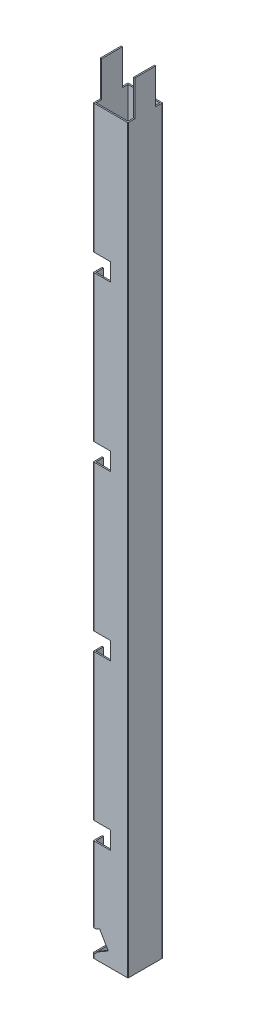
from build123d import *

# Parameters (mm, degrees)
SKETCH1_W           = 37
SKETCH1_H           = 37
BOSS_EXTRUDE1_DEPTH = 899
CUT_EXTRUDE2_DEPTH  = 20
SKETCH4_W           = 8
SKETCH4_H           = 41
CUT_EXTRUDE3_DEPTH  = 901.777997067
SKETCH5_R           = 3.5
CUT_EXTRUDE4_DEPTH  = 10
CUT_EXTRUDE5_DEPTH  = 20


with BuildPart() as part:
    # Sketch1 → Boss-Extrude1 (new body)
    with BuildSketch(Plane(origin=(0, 0, 0), x_dir=(1, 0, 0), z_dir=(0, 1, 0))):
        with BuildLine():
            Line((0.5, 0), (39.5, 0))
            ThreePointArc((39.5, 0), (39.853553391, 0.146446609), (40, 0.5))
            Line((40, 0.5), (40, 39.5))
            ThreePointArc((40, 39.5), (39.853553391, 39.853553391), (39.5, 40))
            Line((39.5, 40), (0.5, 40))
            ThreePointArc((0.5, 40), (0.146446609, 39.853553391), (0, 39.5))
            Line((0, 39.5), (0, 0.5))
            ThreePointArc((0, 0.5), (0.146446609, 0.146446609), (0.5, 0))
        make_face()
        with Locations((20, 20)):
            Rectangle(SKETCH1_W, SKETCH1_H, mode=Mode.SUBTRACT)
    extrude(amount=BOSS_EXTRUDE1_DEPTH)

    # Sketch3 → Cut-Extrude2 (cut)
    with BuildSketch(Plane.XY):
        Polygon((0, 29.014346333), (0, 5.907288086), (3, 5.907288086), (3, 7.639845548), (17.125490967, 15.797587142), (7.072929751, 33.098592085), (3, 30.74639714), (0, 30.74639714), align=None)
    extrude(amount=-CUT_EXTRUDE2_DEPTH, mode=Mode.SUBTRACT)

    # Sketch4 → Cut-Extrude3 (cut, through all)
    with BuildSketch(Plane.ZY):
        with Locations((-4, 878.5)):
            Rectangle(SKETCH4_W, SKETCH4_H)
        with Locations((-36, 878.5)):
            Rectangle(SKETCH4_W, SKETCH4_H)
    extrude(amount=-CUT_EXTRUDE3_DEPTH, mode=Mode.SUBTRACT)

    # Sketch5 → Cut-Extrude4 (cut)
    with BuildSketch(Plane(origin=(0, 0, -40), x_dir=(-1, 0, 0), z_dir=(0, 0, -1))):
        with Locations((-10, 30)):
            Circle(SKETCH5_R)
        with Locations((-10, 15)):
            Circle(SKETCH5_R)
    extrude(amount=-CUT_EXTRUDE4_DEPTH, mode=Mode.SUBTRACT)

    # Sketch6 → Cut-Extrude5 (cut)
    with BuildSketch(Plane.ZY):
        Polygon((0, 708.5), (-20, 708.5), (-20, 668), (-10, 668), (-10, 688), (0, 688), align=None)
        Polygon((0, 518.5), (-20, 518.5), (-20, 478), (-10, 478), (-10, 498), (0, 498), align=None)
        Polygon((0, 328.5), (-20, 328.5), (-20, 288), (-10, 288), (-10, 308), (0, 308), align=None)
        Polygon((0, 138.5), (-20, 138.5), (-20, 98), (-10, 98), (-10, 118), (0, 118), align=None)
    extrude(amount=-CUT_EXTRUDE5_DEPTH, mode=Mode.SUBTRACT)


solid = part.part
